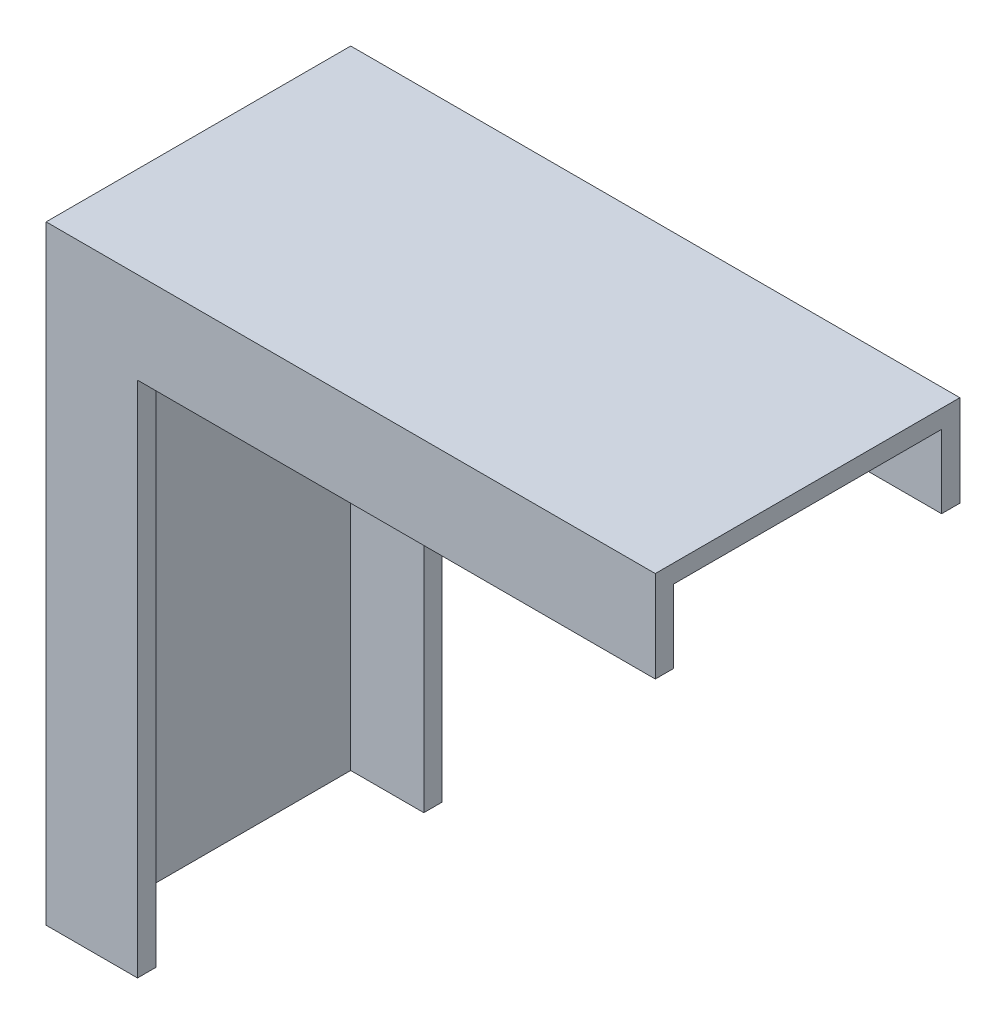
from build123d import *

# Parameters (mm, degrees)
LINEAR_AUSTRAGEN_D_NN1_DEPTH    = 50
SKIZZE3_W                       = 44
SKIZZE3_H                       = 100.666411599
SCHNITT_LINEAR_AUSTRAGEN2_DEPTH = 97


with BuildPart() as part:
    # Skizze1 → Linear-Austragen-Dünn1 (new body)
    with BuildSketch(Plane.XY):
        Polygon((0, 0), (0, 100), (100, 100), (100, 85), (15, 85), (15, 0), align=None)
    extrude(amount=LINEAR_AUSTRAGEN_D_NN1_DEPTH)

    # Skizze3 → Schnitt-Linear austragen2 (cut)
    with BuildSketch(Plane(origin=(100, 0, 0), x_dir=(0, 0, -1), z_dir=(1, 0, 0))):
        with Locations((-25, 46.666794201)):
            Rectangle(SKIZZE3_W, SKIZZE3_H)
    extrude(amount=-SCHNITT_LINEAR_AUSTRAGEN2_DEPTH, mode=Mode.SUBTRACT)


solid = part.part
